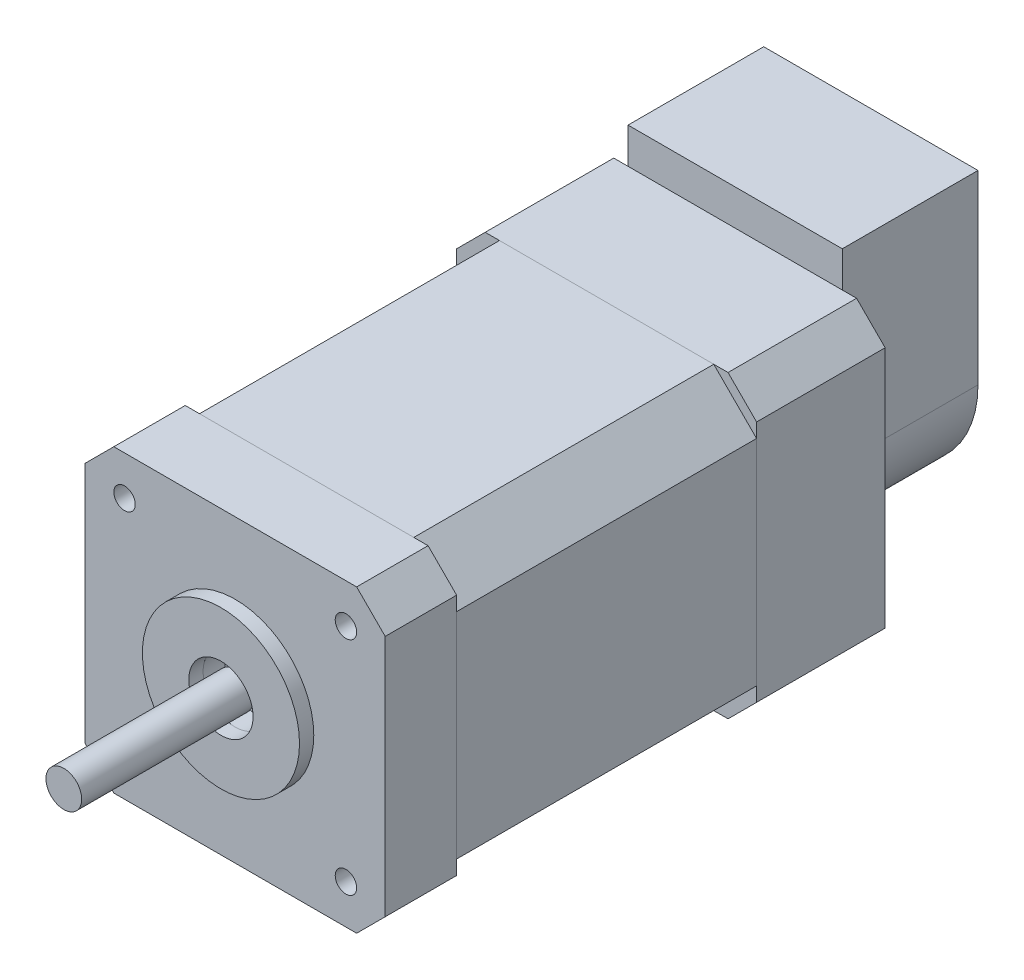
from build123d import *

# Parameters (mm, degrees)
SKETCH_1_W               = 42
SKETCH_1_H               = 42
EXTRUDE_1_DEPTH          = 21
CHAMFER_1_SIZE           = 6
SKETCH_15_W              = 42
SKETCH_15_H              = 42
EXTRUDE_11_DEPTH         = 10
SKETCH_16_W              = 42
SKETCH_16_H              = 42
EXTRUDE_12_DEPTH         = 8.5
SKETCH_17_W              = 42
SKETCH_17_H              = 42
EXTRUDE_13_DEPTH         = 9.5
CHAMFER_2_SIZE           = 4
CHAMFER_3_SIZE           = 4
SKETCH_2_R               = 11
EXTRUDE_2_DEPTH          = 2
SKETCH_3_R               = 4.5
CUT_EXTRUDE_1_DEPTH      = 5
SKETCH_6_R               = 2.5
EXTRUDE_9_DEPTH          = 24
EXTRUDE_10_DEPTH         = 19
SKETCH_8_R               = 1.5
CUT_EXTRUDE_3_DEPTH      = 4.5
PATTERN_CIRCULAR_1_COUNT = 4


with BuildPart() as part:
    # 草圖1 → 填料-伸長1 (new body, symmetric)
    with BuildSketch(Plane.XY):
        Rectangle(SKETCH_1_W, SKETCH_1_H)
    extrude(amount=EXTRUDE_1_DEPTH, both=True)

    # 導角1
    chamfer_1_edges = [part.edges().sort_by_distance(p)[0] for p in [
        (21, -21, 0),
        (-21, -21, 0),
        (-21, 21, 0),
        (21, 21, 0),
    ]]
    chamfer(chamfer_1_edges, length=CHAMFER_1_SIZE)


with BuildPart() as body_2:
    # 草圖15 → 填料-伸長11 (new body)
    with BuildSketch(Plane.XY.offset(21)):
        Rectangle(SKETCH_15_W, SKETCH_15_H)
    extrude(amount=EXTRUDE_11_DEPTH)

    # 導角2
    chamfer_2_edges = [body_2.edges().sort_by_distance(p)[0] for p in [
        (21, -21, 26),
        (-21, -21, 26),
        (-21, 21, 26),
        (21, 21, 26),
    ]]
    chamfer(chamfer_2_edges, length=CHAMFER_2_SIZE)


with BuildPart() as body_3:
    # 草圖16 → 填料-伸長12 (new body)
    with BuildSketch(Plane(origin=(0, 0, -21), x_dir=(-1, 0, 0), z_dir=(0, 0, -1))):
        Rectangle(SKETCH_16_W, SKETCH_16_H)
    extrude(amount=EXTRUDE_12_DEPTH)

    # 草圖17 → 填料-伸長13 (add)
    with BuildSketch(Plane.XY.offset(-29.5)):
        Rectangle(SKETCH_17_W, SKETCH_17_H)
    extrude(amount=-EXTRUDE_13_DEPTH)

    # 導角3
    chamfer_3_edges = [body_3.edges().sort_by_distance(p)[0] for p in [
        (-21, -21, -30),
        (21, -21, -30),
        (21, 21, -30),
        (-21, 21, -30),
    ]]
    chamfer(chamfer_3_edges, length=CHAMFER_3_SIZE)


with BuildPart() as body_4:
    # 草圖2 → 填料-伸長2 (new body)
    with BuildSketch(Plane.XY.offset(31)):
        Circle(SKETCH_2_R)
    extrude(amount=EXTRUDE_2_DEPTH)


with BuildPart() as cut_extrude_1_tool:
    # 草圖3 → 除料-伸長1 (new body)
    with BuildSketch(Plane.XY.offset(33)):
        Circle(SKETCH_3_R)
    extrude(amount=-CUT_EXTRUDE_1_DEPTH)


with BuildPart() as body_2_1:
    add(body_2.part)

    # 除料-伸長1: cut by cut_extrude_1_tool
    add(cut_extrude_1_tool.part, mode=Mode.SUBTRACT)

    # 草圖8 → 除料-伸長3 (cut)
    with BuildSketch(Plane.XY.offset(31)):
        with Locations((-15.5, 15.5)):
            Circle(SKETCH_8_R)
    cut_extrude_3 = extrude(amount=-CUT_EXTRUDE_3_DEPTH, mode=Mode.SUBTRACT)

    # 環狀複製排列1: 除料-伸長3 ×4 about axis
    pattern_circular_1_axis = Axis((0, 0, 0), (0, 0, 1))
    for i in range(1, PATTERN_CIRCULAR_1_COUNT):
        add(cut_extrude_3.rotate(pattern_circular_1_axis, i * 360 / PATTERN_CIRCULAR_1_COUNT), mode=Mode.SUBTRACT)


with BuildPart() as body_4_1:
    add(body_4.part)

    # 除料-伸長1: cut by cut_extrude_1_tool
    add(cut_extrude_1_tool.part, mode=Mode.SUBTRACT)


with BuildPart() as body_5:
    # 草圖6 → 填料-伸長9 (new body)
    with BuildSketch(Plane.XY.offset(31)):
        Circle(SKETCH_6_R)
    extrude(amount=EXTRUDE_9_DEPTH)


with BuildPart() as body_6:
    # 草圖9 → 填料-伸長10 (new body)
    with BuildSketch(Plane(origin=(0, 0, -39), x_dir=(-1, 0, 0), z_dir=(0, 0, -1))):
        with BuildLine():
            Line((-15, 0), (-15, 26))
            Line((-15, 26), (15, 26))
            Line((15, 26), (15, 0))
            ThreePointArc((15, 0), (0, -15), (-15, 0))
        make_face()
    extrude(amount=EXTRUDE_10_DEPTH)


solid = Compound([part.part, body_3.part, body_2_1.part, body_4_1.part, body_5.part, body_6.part])
